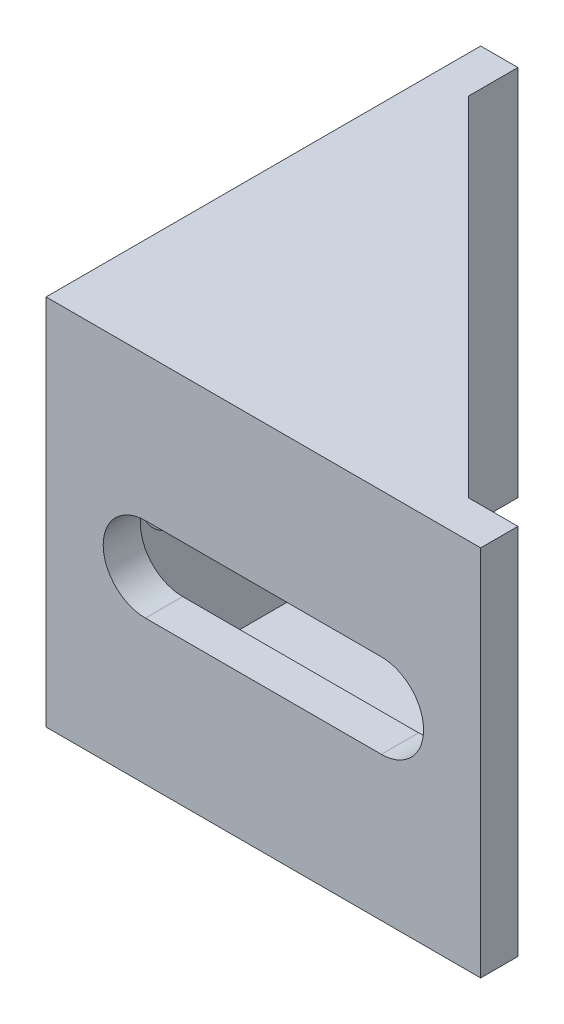
from build123d import *

# Parameters (mm, degrees)
BOSS_EXTRUDE1_DEPTH = 26
BOSS_EXTRUDE2_DEPTH = 2
BOSS_EXTRUDE3_DEPTH = 2
CUT_EXTRUDE1_DEPTH  = 4
CUT_EXTRUDE2_DEPTH  = 4


with BuildPart() as part:
    # Sketch1 → Boss-Extrude1 (new body)
    with BuildSketch(Plane(origin=(0, 0, 0), x_dir=(1, 0, 0), z_dir=(0, 1, 0))):
        Polygon((0, 0), (0, 35), (3, 35), (3, 3), (35, 3), (35, 0), align=None)
    extrude(amount=BOSS_EXTRUDE1_DEPTH)

    # Sketch2 → Boss-Extrude2 (add)
    with BuildSketch(Plane(origin=(0, 26, 0), x_dir=(1, 0, 0), z_dir=(0, 1, 0))):
        Polygon((3, 35), (0, 35), (0, 0), (35, 0), (35, 3), (31, 3), (3, 31), align=None)
    extrude(amount=BOSS_EXTRUDE2_DEPTH)

    # Sketch3 → Boss-Extrude3 (add)
    with BuildSketch(Plane.XZ):
        Polygon((0, 0), (0, -35), (3, -35), (3, -31), (31, -3), (35, -3), (35, 0), align=None)
    extrude(amount=BOSS_EXTRUDE3_DEPTH)

    # Sketch4 → Cut-Extrude1 (cut, through all)
    with BuildSketch(Plane(origin=(0, 0, -3), x_dir=(-1, 0, 0), z_dir=(0, 0, -1))):
        with BuildLine():
            Line((-27, 16.4), (-8, 16.4))
            ThreePointArc((-8, 16.4), (-4.6, 13), (-8, 9.6))
            Line((-8, 9.6), (-27, 9.6))
            ThreePointArc((-27, 9.6), (-30.4, 13), (-27, 16.4))
        make_face()
    extrude(amount=-CUT_EXTRUDE1_DEPTH, mode=Mode.SUBTRACT)

    # Sketch5 → Cut-Extrude2 (cut, through all)
    with BuildSketch(Plane(origin=(3, 0, 0), x_dir=(0, 0, -1), z_dir=(1, 0, 0))):
        with BuildLine():
            Line((8, 16.4), (27, 16.4))
            ThreePointArc((27, 16.4), (30.4, 13), (27, 9.6))
            Line((27, 9.6), (8, 9.6))
            ThreePointArc((8, 9.6), (4.6, 13), (8, 16.4))
        make_face()
    extrude(amount=-CUT_EXTRUDE2_DEPTH, mode=Mode.SUBTRACT)


solid = part.part
